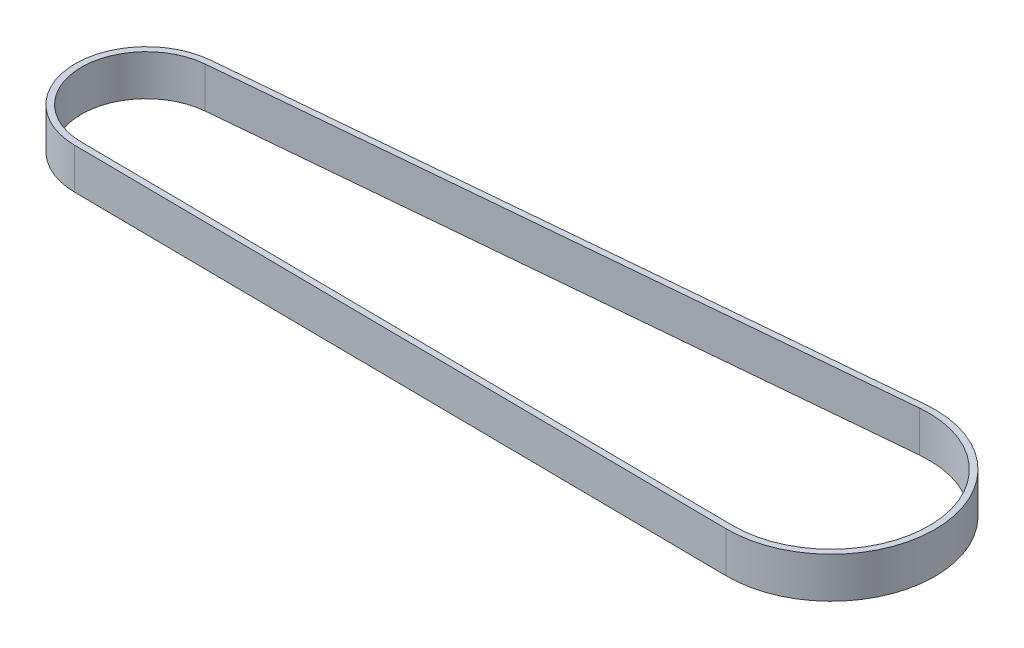
from build123d import *

# Parameters (mm, degrees)
BOSS_EXTRUDE1_DEPTH = 10


with BuildPart() as part:
    # Sketch1 → Boss-Extrude1 (new body)
    with BuildSketch(Plane(origin=(0, 0, 0), x_dir=(1, 0, 0), z_dir=(0, 1, 0))):
        with BuildLine():
            Line((-72.889281859, 10.847862546), (87.973934406, 25.396347929))
            ThreePointArc((87.973934406, 25.396347929), (115.750200726, 1.02433139), (90.020035451, -25.498767144))
            Line((90.020035451, -25.498767144), (-71.491915203, -23.910507218))
            ThreePointArc((-71.491915203, -23.910507218), (-88.721613366, -7.195907271), (-72.889281859, 10.847862546))
        make_face()
        with BuildLine():
            Line((-72.754173138, 9.353959727), (88.109043127, 23.902445109))
            ThreePointArc((88.109043127, 23.902445109), (114.251411427, 0.964076602), (90.034785287, -23.998839664))
            Line((90.034785287, -23.998839664), (-71.477165368, -22.410579739))
            ThreePointArc((-71.477165368, -22.410579739), (-87.222824068, -7.135652483), (-72.754173138, 9.353959727))
        make_face(mode=Mode.SUBTRACT)
    extrude(amount=BOSS_EXTRUDE1_DEPTH)


solid = part.part
